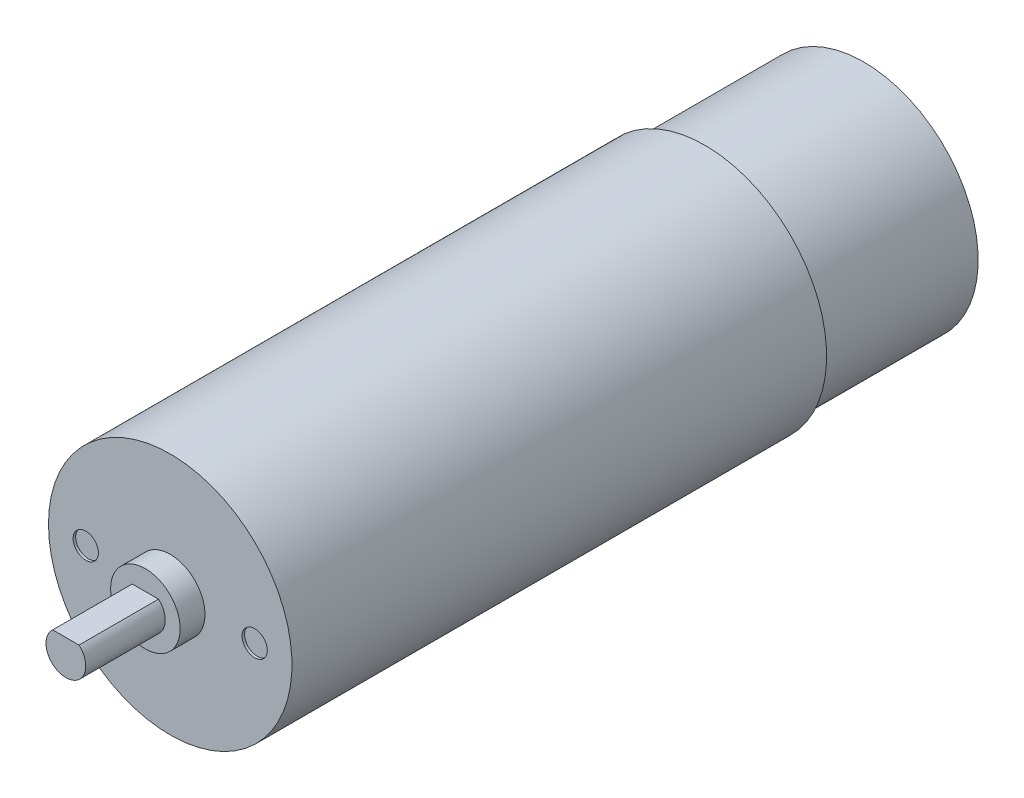
from build123d import *

# Parameters (mm, degrees)
SKETCH1_R           = 2
BOSS_EXTRUDE1_DEPTH = 8
SKETCH2_R           = 3.5
BOSS_EXTRUDE2_DEPTH = 2.5
SKETCH3_R           = 12.25
BOSS_EXTRUDE3_DEPTH = 53.8
SKETCH4_R           = 1.27
CUT_EXTRUDE1_DEPTH  = 0.254
SKETCH5_R           = 11.5
BOSS_EXTRUDE4_DEPTH = 16
CUT_EXTRUDE2_DEPTH  = 8


with BuildPart() as part:
    # Sketch1 → Boss-Extrude1 (new body)
    with BuildSketch(Plane.XY):
        Circle(SKETCH1_R)
    extrude(amount=BOSS_EXTRUDE1_DEPTH)

    # Sketch2 → Boss-Extrude2 (add)
    with BuildSketch(Plane(origin=(0, 0, 0), x_dir=(-1, 0, 0), z_dir=(0, 0, -1))):
        Circle(SKETCH2_R)
    extrude(amount=BOSS_EXTRUDE2_DEPTH)

    # Sketch3 → Boss-Extrude3 (add)
    with BuildSketch(Plane(origin=(0, 0, -2.5), x_dir=(-1, 0, 0), z_dir=(0, 0, -1))):
        Circle(SKETCH3_R)
    extrude(amount=BOSS_EXTRUDE3_DEPTH)

    # Sketch4 → Cut-Extrude1 (cut)
    with BuildSketch(Plane.XY.offset(-2.5)):
        with Locations((8.5, 0)):
            Circle(SKETCH4_R)
        with Locations((-8.5, 0)):
            Circle(SKETCH4_R)
    extrude(amount=-CUT_EXTRUDE1_DEPTH, mode=Mode.SUBTRACT)

    # Sketch5 → Boss-Extrude4 (add)
    with BuildSketch(Plane(origin=(0, 0, -56.3), x_dir=(-1, 0, 0), z_dir=(0, 0, -1))):
        Circle(SKETCH5_R)
    extrude(amount=BOSS_EXTRUDE4_DEPTH)

    # Sketch6 → Cut-Extrude2 (cut)
    with BuildSketch(Plane.XY.offset(8)):
        with BuildLine():
            Line((-1.322875656, 1.5), (1.322875656, 1.5))
            ThreePointArc((1.322875656, 1.5), (0, 2), (-1.322875656, 1.5))
        make_face()
    extrude(amount=-CUT_EXTRUDE2_DEPTH, mode=Mode.SUBTRACT)


solid = part.part
